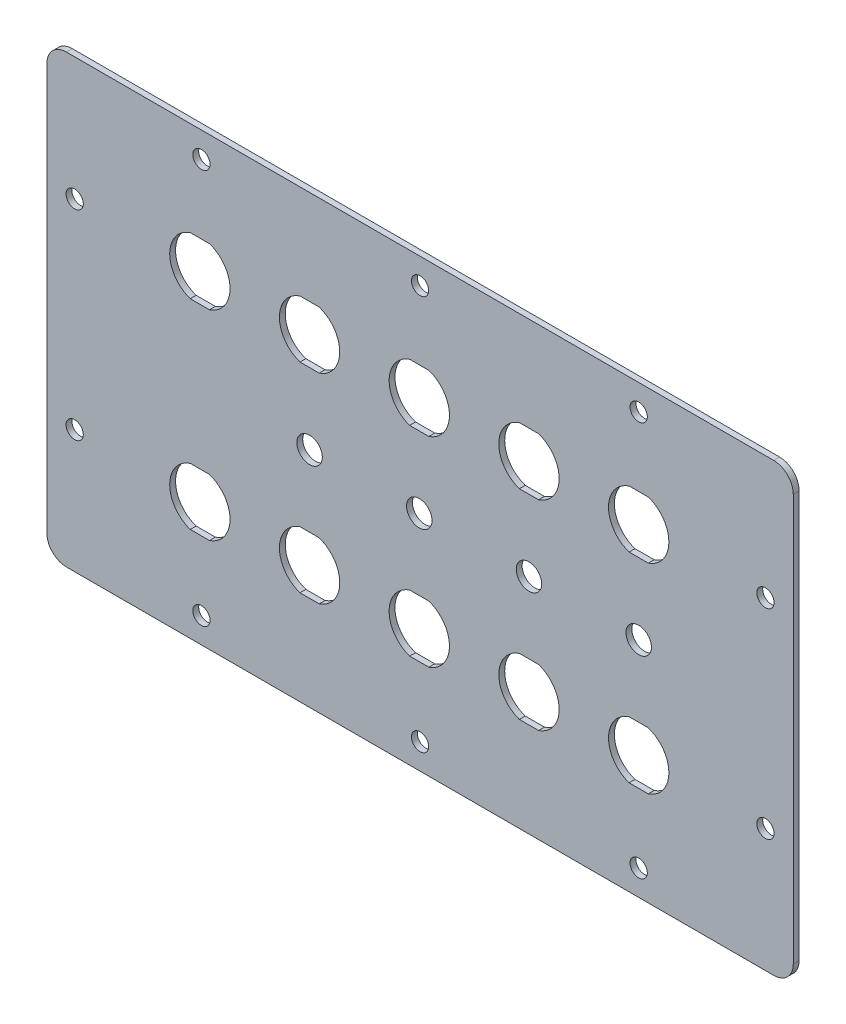
from build123d import *

# Parameters (mm, degrees)
SKETCH1_W           = 190.5
SKETCH1_H           = 113.82
BOSS_EXTRUDE1_DEPTH = 1.5
SKETCH2_R           = 2.2
CUT_EXTRUDE1_DEPTH  = 2.5
SKETCH3_R           = 2.2
CUT_EXTRUDE2_DEPTH  = 2.5
SKETCH4_R           = 3.25
CUT_EXTRUDE3_DEPTH  = 2.5
FILLET1_R           = 5
FILLET2_R           = 5


with BuildPart() as part:
    # Sketch1 → Boss-Extrude1 (new body)
    with BuildSketch(Plane.XY):
        with Locations((95.25, 56.91)):
            Rectangle(SKETCH1_W, SKETCH1_H)
    extrude(amount=BOSS_EXTRUDE1_DEPTH)

    # Sketch2 → Cut-Extrude1 (cut, through all)
    with BuildSketch(Plane(origin=(0, 0, 0), x_dir=(-1, 0, 0), z_dir=(0, 0, -1))):
        with Locations((-183.4, 82.41)):
            Circle(SKETCH2_R)
        with Locations((-183.4, 31.41)):
            Circle(SKETCH2_R)
        with Locations((-7.1, 31.41)):
            Circle(SKETCH2_R)
        with Locations((-7.1, 82.41)):
            Circle(SKETCH2_R)
    extrude(amount=-CUT_EXTRUDE1_DEPTH, mode=Mode.SUBTRACT)

    # Sketch3 → Cut-Extrude2 (cut, through all)
    with BuildSketch(Plane(origin=(0, 0, 0), x_dir=(-1, 0, 0), z_dir=(0, 0, -1))):
        with Locations((-95.25, 107.31)):
            Circle(SKETCH3_R)
        with Locations((-39.45, 107.31)):
            Circle(SKETCH3_R)
        with Locations((-151.05, 107.31)):
            Circle(SKETCH3_R)
        with Locations((-39.45, 6.51)):
            Circle(SKETCH3_R)
        with Locations((-95.25, 6.51)):
            Circle(SKETCH3_R)
        with Locations((-151.05, 6.51)):
            Circle(SKETCH3_R)
    extrude(amount=-CUT_EXTRUDE2_DEPTH, mode=Mode.SUBTRACT)

    # Sketch4 → Cut-Extrude3 (cut, through all)
    with BuildSketch(Plane(origin=(0, 0, 0), x_dir=(-1, 0, 0), z_dir=(0, 0, -1))):
        with Locations((-151.05, 56.91)):
            Circle(SKETCH4_R)
        with Locations((-123.05, 56.91)):
            Circle(SKETCH4_R)
        with Locations((-95.05, 56.91)):
            Circle(SKETCH4_R)
        with Locations((-67.05, 56.91)):
            Circle(SKETCH4_R)
        with BuildLine():
            Line((-153.499489743, 89.71), (-148.600510257, 89.71))
            ThreePointArc((-148.600510257, 89.71), (-143.35, 82.41), (-148.600510257, 75.11))
            Line((-148.600510257, 75.11), (-153.499489743, 75.11))
            ThreePointArc((-153.499489743, 75.11), (-158.75, 82.41), (-153.499489743, 89.71))
        make_face()
        with BuildLine():
            Line((-153.499489743, 24.11), (-148.600510257, 24.11))
            ThreePointArc((-148.600510257, 24.11), (-143.35, 31.41), (-148.600510257, 38.71))
            Line((-148.600510257, 38.71), (-153.499489743, 38.71))
            ThreePointArc((-153.499489743, 38.71), (-158.75, 31.41), (-153.499489743, 24.11))
        make_face()
        with BuildLine():
            Line((-125.499489743, 75.11), (-120.600510257, 75.11))
            ThreePointArc((-120.600510257, 75.11), (-115.35, 82.41), (-120.600510257, 89.71))
            Line((-120.600510257, 89.71), (-125.499489743, 89.71))
            ThreePointArc((-125.499489743, 89.71), (-130.75, 82.41), (-125.499489743, 75.11))
        make_face()
        with BuildLine():
            Line((-125.499489743, 38.71), (-120.600510257, 38.71))
            ThreePointArc((-120.600510257, 38.71), (-115.35, 31.41), (-120.600510257, 24.11))
            Line((-120.600510257, 24.11), (-125.499489743, 24.11))
            ThreePointArc((-125.499489743, 24.11), (-130.75, 31.41), (-125.499489743, 38.71))
        make_face()
        with BuildLine():
            Line((-97.499489743, 75.11), (-92.600510257, 75.11))
            ThreePointArc((-92.600510257, 75.11), (-87.35, 82.41), (-92.600510257, 89.71))
            Line((-92.600510257, 89.71), (-97.499489743, 89.71))
            ThreePointArc((-97.499489743, 89.71), (-102.75, 82.41), (-97.499489743, 75.11))
        make_face()
        with BuildLine():
            Line((-97.499489743, 38.71), (-92.600510257, 38.71))
            ThreePointArc((-92.600510257, 38.71), (-87.35, 31.41), (-92.600510257, 24.11))
            Line((-92.600510257, 24.11), (-97.499489743, 24.11))
            ThreePointArc((-97.499489743, 24.11), (-102.75, 31.41), (-97.499489743, 38.71))
        make_face()
        with BuildLine():
            Line((-69.499489743, 75.11), (-64.600510257, 75.11))
            ThreePointArc((-64.600510257, 75.11), (-59.35, 82.41), (-64.600510257, 89.71))
            Line((-64.600510257, 89.71), (-69.499489743, 89.71))
            ThreePointArc((-69.499489743, 89.71), (-74.75, 82.41), (-69.499489743, 75.11))
        make_face()
        with BuildLine():
            Line((-69.499489743, 38.71), (-64.600510257, 38.71))
            ThreePointArc((-64.600510257, 38.71), (-59.35, 31.41), (-64.600510257, 24.11))
            Line((-64.600510257, 24.11), (-69.499489743, 24.11))
            ThreePointArc((-69.499489743, 24.11), (-74.75, 31.41), (-69.499489743, 38.71))
        make_face()
        with BuildLine():
            Line((-41.499489743, 75.11), (-36.600510257, 75.11))
            ThreePointArc((-36.600510257, 75.11), (-31.35, 82.41), (-36.600510257, 89.71))
            Line((-36.600510257, 89.71), (-41.499489743, 89.71))
            ThreePointArc((-41.499489743, 89.71), (-46.75, 82.41), (-41.499489743, 75.11))
        make_face()
        with BuildLine():
            Line((-41.499489743, 38.71), (-36.600510257, 38.71))
            ThreePointArc((-36.600510257, 38.71), (-31.35, 31.41), (-36.600510257, 24.11))
            Line((-36.600510257, 24.11), (-41.499489743, 24.11))
            ThreePointArc((-41.499489743, 24.11), (-46.75, 31.41), (-41.499489743, 38.71))
        make_face()
    extrude(amount=-CUT_EXTRUDE3_DEPTH, mode=Mode.SUBTRACT)

    # Fillet1
    fillet1_edges = [part.edges().sort_by_distance(p)[0] for p in [
        (190.5, 113.82, 0.75),
        (190.5, 0, 0.75),
    ]]
    fillet(fillet1_edges, radius=FILLET1_R)

    # Fillet2
    fillet2_edges = [part.edges().sort_by_distance(p)[0] for p in [
        (0, 113.82, 0.75),
        (0, 0, 0.75),
    ]]
    fillet(fillet2_edges, radius=FILLET2_R)


solid = part.part
